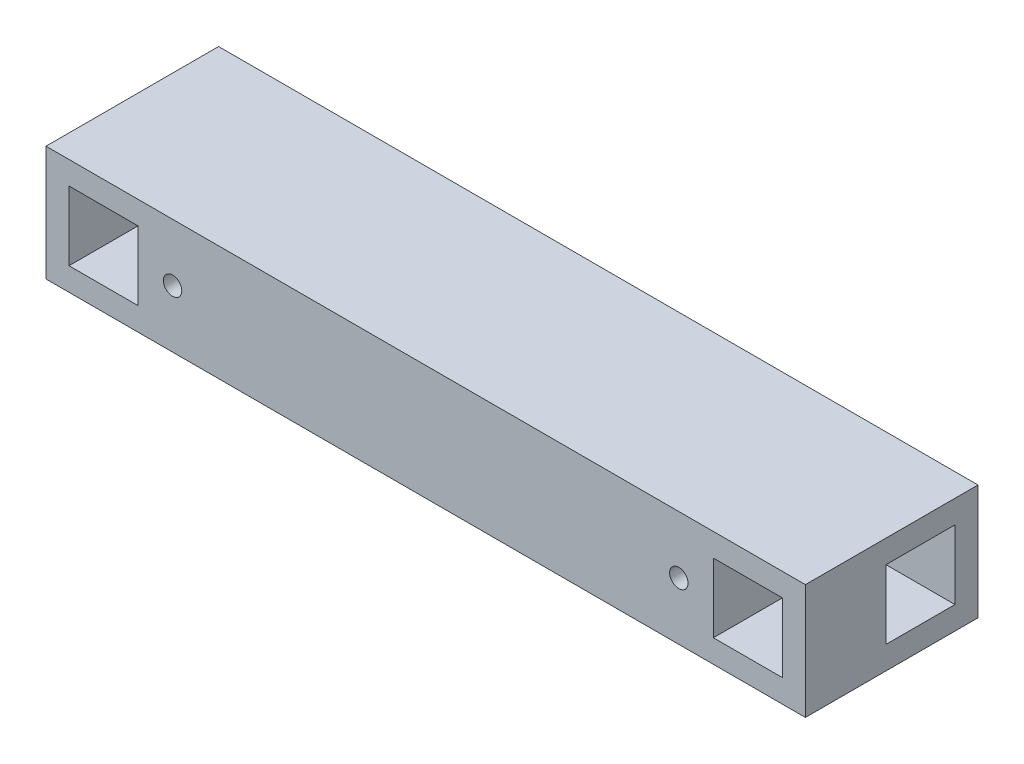
from build123d import *

# Parameters (mm, degrees)
CROQUIS1_W              = 330
CROQUIS1_H              = 50
SALIENTE_EXTRUIR1_DEPTH = 75
CROQUIS2_R              = 4
CROQUIS2_W              = 30
CROQUIS2_H              = 30
CORTAR_EXTRUIR1_DEPTH   = 30
CROQUIS3_W              = 30
CROQUIS3_H              = 30
CORTAR_EXTRUIR2_DEPTH   = 331


with BuildPart() as part:
    # Croquis1 → Saliente-Extruir1 (new body)
    with BuildSketch(Plane.XY):
        Rectangle(CROQUIS1_W, CROQUIS1_H)
    extrude(amount=SALIENTE_EXTRUIR1_DEPTH)

    # Croquis2 → Cortar-Extruir1 (cut)
    with BuildSketch(Plane.XY.offset(75)):
        with Locations((-110, 0)):
            Circle(CROQUIS2_R)
        with Locations((110, 0)):
            Circle(CROQUIS2_R)
        with Locations((-140, 0)):
            Rectangle(CROQUIS2_W, CROQUIS2_H)
        with Locations((140, 0)):
            Rectangle(CROQUIS2_W, CROQUIS2_H)
    extrude(amount=-CORTAR_EXTRUIR1_DEPTH, mode=Mode.SUBTRACT)

    # Croquis3 → Cortar-Extruir2 (cut, through all)
    with BuildSketch(Plane.ZY.offset(165)):
        with Locations((25, 0)):
            Rectangle(CROQUIS3_W, CROQUIS3_H)
    extrude(amount=-CORTAR_EXTRUIR2_DEPTH, mode=Mode.SUBTRACT)


solid = part.part
